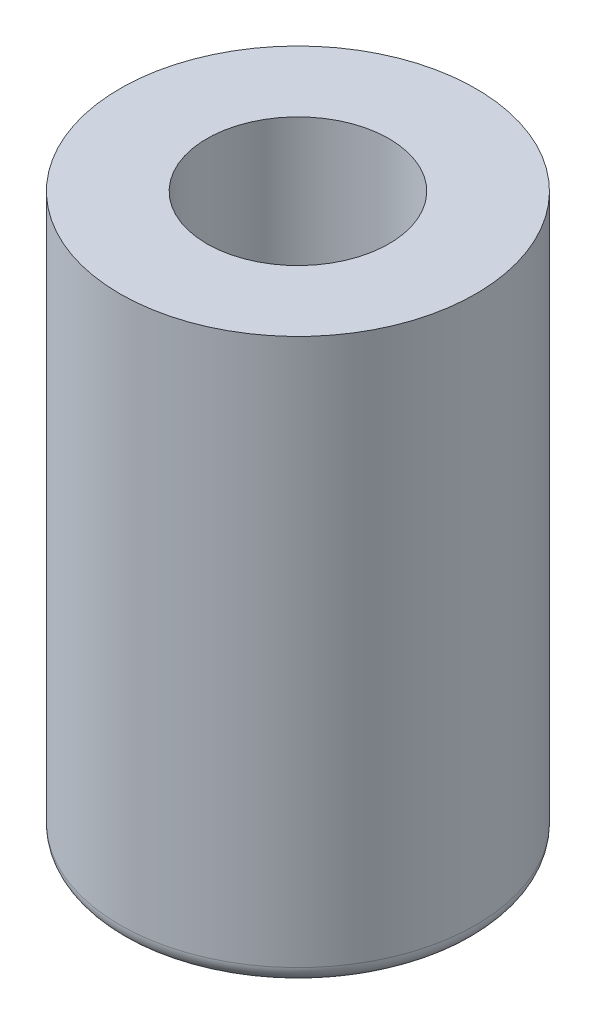
from build123d import *

# Parameters (mm, degrees)
SKETCH_1_R          = 2.05
SKETCH_1_R_2        = 1.05
EXTRUDE_1_DEPTH     = 7.5
FILLET_1_R          = 0.2
SKETCH_2_R          = 3.05
CUT_EXTRUDE_1_DEPTH = 1


with BuildPart() as part:
    # 草图1 → 凸台-拉伸1 (new body)
    with BuildSketch(Plane(origin=(0, 0, 0), x_dir=(1, 0, 0), z_dir=(0, 1, 0))):
        Circle(SKETCH_1_R)
        Circle(SKETCH_1_R_2, mode=Mode.SUBTRACT)
    extrude(amount=EXTRUDE_1_DEPTH)

    # 圆角1
    fillet_1_edges = [part.edges().sort_by_distance(p)[0] for p in [
        (-2.05, 0, 0),
        (-2.05, 7.5, 0),
        (-1.05, 0, 0),
        (-1.05, 7.5, 0),
    ]]
    fillet(fillet_1_edges, radius=FILLET_1_R)

    # 草图2 → 切除-拉伸1 (cut)
    with BuildSketch(Plane(origin=(0, 7.5, 0), x_dir=(1, 0, 0), z_dir=(0, 1, 0))):
        Circle(SKETCH_2_R)
    extrude(amount=-CUT_EXTRUDE_1_DEPTH, mode=Mode.SUBTRACT)


solid = part.part
